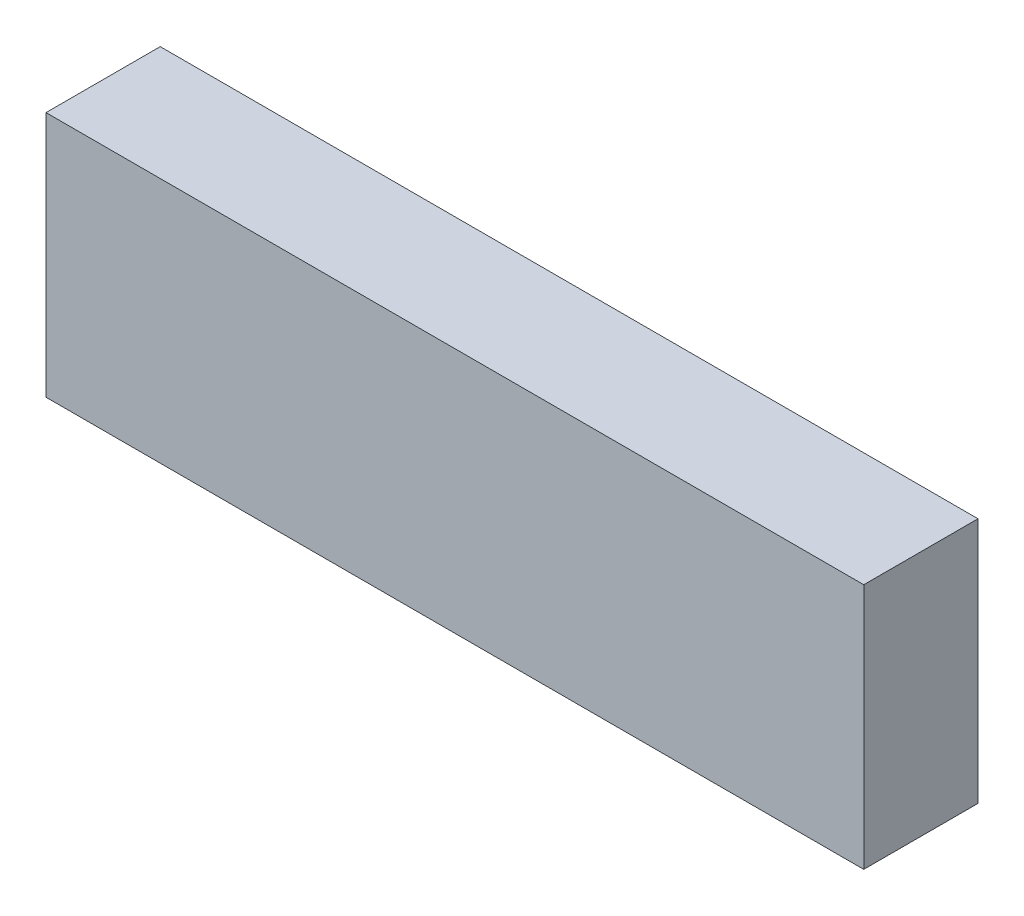
from build123d import *

# Parameters (mm, degrees)
SKETCH_1_W      = 136
SKETCH_1_H      = 41
EXTRUDE_1_DEPTH = 9.5


with BuildPart() as part:
    # Эскиз1 → Бобышка-Вытянуть1 (new body, symmetric)
    with BuildSketch(Plane.XY):
        Rectangle(SKETCH_1_W, SKETCH_1_H)
    extrude(amount=EXTRUDE_1_DEPTH, both=True)


solid = part.part
